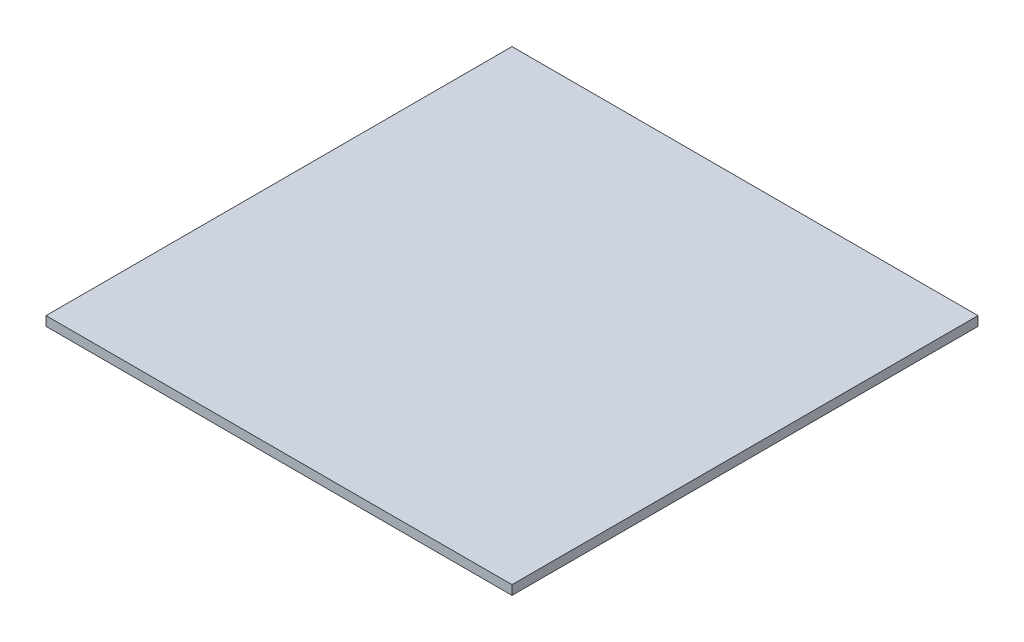
from build123d import *

# Parameters (mm, degrees)
SKETCH1_W           = 1270
SKETCH1_H           = 1270
BOSS_EXTRUDE1_DEPTH = 25.4


with BuildPart() as part:
    # Sketch1 → Boss-Extrude1 (new body)
    with BuildSketch(Plane(origin=(0, 0, 0), x_dir=(1, 0, 0), z_dir=(0, 1, 0))):
        with Locations((635, 635)):
            Rectangle(SKETCH1_W, SKETCH1_H)
    extrude(amount=-BOSS_EXTRUDE1_DEPTH)


solid = part.part
